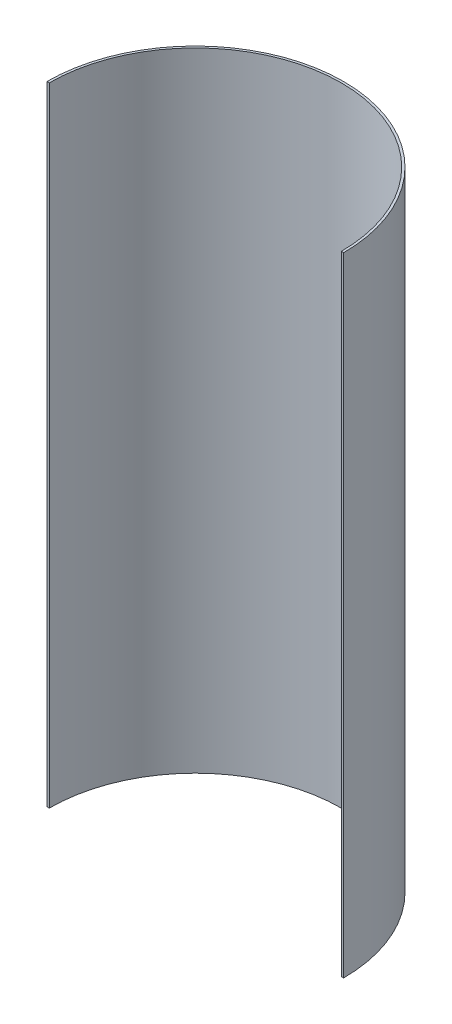
from build123d import *

# Parameters (mm, degrees)
EXTRUDE_THIN1_DEPTH = 685.8


with BuildPart() as part:
    # Sketch1 → Extrude-Thin1 (new body)
    with BuildSketch(Plane(origin=(0, 0, 0), x_dir=(1, 0, 0), z_dir=(0, 1, 0))):
        with BuildLine():
            ThreePointArc((-158.769620285, 98.920861628), (3.155379715, 260.845861628), (165.080379715, 98.920861628))
            Line((165.080379715, 98.920861628), (162.540379715, 98.920861628))
            ThreePointArc((162.540379715, 98.920861628), (3.155379715, 258.305861628), (-156.229620285, 98.920861628))
            Line((-156.229620285, 98.920861628), (-158.769620285, 98.920861628))
        make_face()
    extrude(amount=EXTRUDE_THIN1_DEPTH)


solid = part.part
